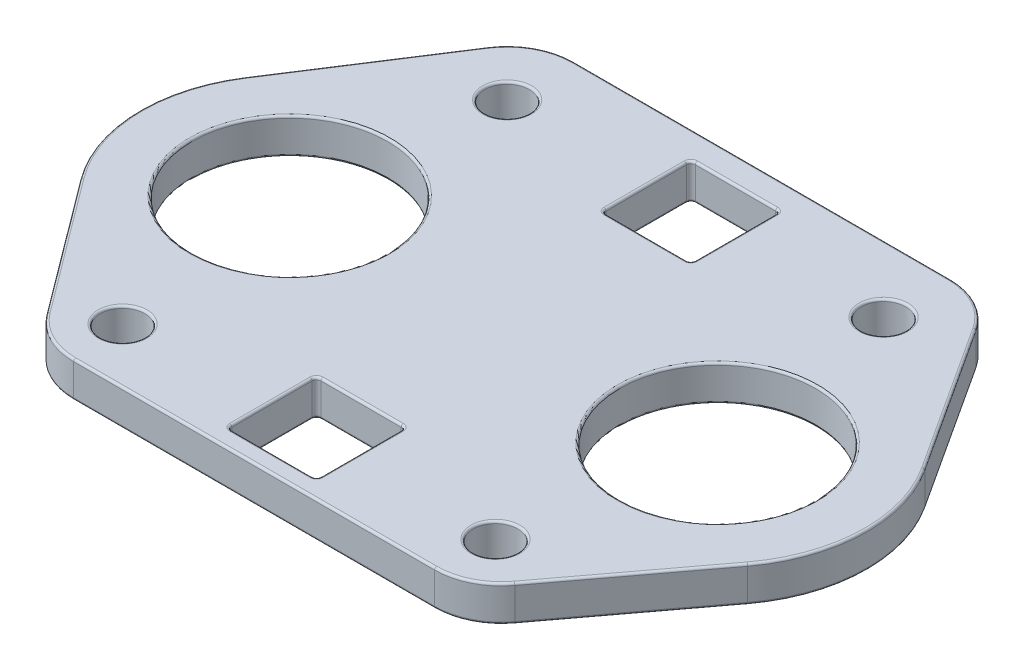
from build123d import *

# Parameters (mm, degrees)
SKETCH_1_R          = 22
EXTRUDE_1_DEPTH     = 8
SKETCH_2_R          = 5
CUT_EXTRUDE_1_DEPTH = 9
SKETCH_4_R          = 5
CUT_EXTRUDE_2_DEPTH = 9
CUT_EXTRUDE_3_DEPTH = 9
FILLET_1_R          = 0.5


with BuildPart() as part:
    # 草图1 → 凸台-拉伸1 (new body)
    with BuildSketch(Plane(origin=(0, 0, 0), x_dir=(1, 0, 0), z_dir=(0, 1, 0))):
        with BuildLine():
            Line((5.773348871, 58), (90.226343487, 58))
            ThreePointArc((90.226343487, 58), (97.379937488, 56.184312377), (102.801705878, 51.176812382))
            Line((102.801705878, 51.176812382), (124.168650202, 18.315954689))
            ThreePointArc((124.168650202, 18.315954689), (129.580975857, -1.124771476), (122.879932553, -20.159768757))
            Line((122.879932553, -20.159768757), (100.499998387, -49.999948383))
            ThreePointArc((100.499998387, -49.999948383), (95.208192461, -54.416393438), (88.499959674, -56))
            Line((88.499959674, -56), (7.520896703, -56))
            ThreePointArc((7.520896703, -56), (0.797752805, -54.408927479), (-4.499123157, -49.973244817))
            Line((-4.499123157, -49.973244817), (-26.844802361, -20.040314944))
            ThreePointArc((-26.844802361, -20.040314944), (-33.481155729, -1.126875307), (-28.131519346, 18.189976804))
            Line((-28.131519346, 18.189976804), (-6.822810963, 51.144738021))
            ThreePointArc((-6.822810963, 51.144738021), (-1.397039183, 56.175186342), (5.773348871, 58))
        make_face()
        Circle(SKETCH_1_R, mode=Mode.SUBTRACT)
        with Locations((96, 0)):
            Circle(SKETCH_1_R, mode=Mode.SUBTRACT)
    extrude(amount=EXTRUDE_1_DEPTH)

    # 草图2 → 切除-拉伸1 (cut, through all)
    with BuildSketch(Plane.XZ):
        with Locations((5.773348871, -43)):
            Circle(SKETCH_2_R)
        with Locations((90.226343487, -43)):
            Circle(SKETCH_2_R)
    extrude(amount=-CUT_EXTRUDE_1_DEPTH, mode=Mode.SUBTRACT)

    # 草图4 → 切除-拉伸2 (cut, through all)
    with BuildSketch(Plane(origin=(0, 8, 0), x_dir=(1, 0, 0), z_dir=(0, 1, 0))):
        with Locations((6.176267924, -43.681785496)):
            Circle(SKETCH_4_R)
        with Locations((89.841606232, -43.683278688)):
            Circle(SKETCH_4_R)
    extrude(amount=-CUT_EXTRUDE_2_DEPTH, mode=Mode.SUBTRACT)

    # 草图5 → 切除-拉伸3 (cut, through all)
    with BuildSketch(Plane(origin=(0, 8, 0), x_dir=(1, 0, 0), z_dir=(0, 1, 0))):
        with BuildLine():
            Line((39, -32), (57, -32))
            ThreePointArc((57, -32), (57.707106781, -32.292893219), (58, -33))
            Line((58, -33), (58, -51))
            ThreePointArc((58, -51), (57.707106781, -51.707106781), (57, -52))
            Line((57, -52), (39, -52))
            ThreePointArc((39, -52), (38.292893219, -51.707106781), (38, -51))
            Line((38, -51), (38, -33))
            ThreePointArc((38, -33), (38.292893219, -32.292893219), (39, -32))
        make_face()
        with BuildLine():
            Line((39, 52), (57, 52))
            ThreePointArc((57, 52), (57.707106781, 51.707106781), (58, 51))
            Line((58, 51), (58, 33))
            ThreePointArc((58, 33), (57.707106781, 32.292893219), (57, 32))
            Line((57, 32), (39, 32))
            ThreePointArc((39, 32), (38.292893219, 32.292893219), (38, 33))
            Line((38, 33), (38, 51))
            ThreePointArc((38, 51), (38.292893219, 51.707106781), (39, 52))
        make_face()
    extrude(amount=-CUT_EXTRUDE_3_DEPTH, mode=Mode.SUBTRACT)

    # 圆角1
    fillet_1_edges = [part.edges().sort_by_distance(p)[0] for p in [
        (113.48517804, 0, -34.746383536),
        (129.580975857, 0, 1.124771476),
        (-1.397039183, 8, -56.175186342),
        (111.68996547, 0, 35.07985857),
        (95.208192461, 0, 54.416393438),
        (48.010428189, 0, 56),
        (0.797752805, 0, 54.408927479),
        (-15.671962759, 0, 35.006779881),
        (-33.481155729, 0, 1.126875307),
        (-17.477165155, 0, -34.667357413),
        (-1.397039183, 0, -56.175186342),
        (47.999846179, 0, -58),
        (97.379937488, 0, -56.184312377),
        (-17.477165155, 8, -34.667357413),
        (-33.481155729, 8, 1.126875307),
        (-15.671962759, 8, 35.006779881),
        (0.797752805, 8, 54.408927479),
        (-22, 0, 0),
        (-22, 8, 0),
        (48.010428189, 8, 56),
        (74, 0, 0),
        (74, 8, 0),
        (95.208192461, 8, 54.416393438),
        (111.68996547, 8, 35.07985857),
        (129.580975857, 8, 1.124771476),
        (0.773348871, 8, -43),
        (0.773348871, 0, -43),
        (85.226343487, 8, -43),
        (85.226343487, 0, -43),
        (113.48517804, 8, -34.746383536),
        (97.379937488, 8, -56.184312377),
        (1.176267924, 0, 43.681785496),
        (1.176267924, 8, 43.681785496),
        (84.841606232, 0, 43.683278688),
        (84.841606232, 8, 43.683278688),
        (38.292893219, 0, -32.292893219),
        (38, 0, -42),
        (38.292893219, 0, -51.707106781),
        (48, 0, -52),
        (57.707106781, 0, -51.707106781),
        (58, 0, -42),
        (57.707106781, 0, -32.292893219),
        (48, 0, -32),
        (38.292893219, 8, -32.292893219),
        (48, 8, -32),
        (57.707106781, 8, -32.292893219),
        (58, 8, -42),
        (57.707106781, 8, -51.707106781),
        (48, 8, -52),
        (38.292893219, 8, -51.707106781),
        (38, 8, -42),
        (47.999846179, 8, -58),
        (38.292893219, 0, 32.292893219),
        (48, 0, 32),
        (57.707106781, 0, 32.292893219),
        (58, 0, 42),
        (57.707106781, 0, 51.707106781),
        (48, 0, 52),
        (38.292893219, 0, 51.707106781),
        (38, 0, 42),
        (38.292893219, 8, 32.292893219),
        (38, 8, 42),
        (38.292893219, 8, 51.707106781),
        (48, 8, 52),
        (57.707106781, 8, 51.707106781),
        (58, 8, 42),
        (57.707106781, 8, 32.292893219),
        (48, 8, 32),
    ]]
    fillet(fillet_1_edges, radius=FILLET_1_R)


solid = part.part
